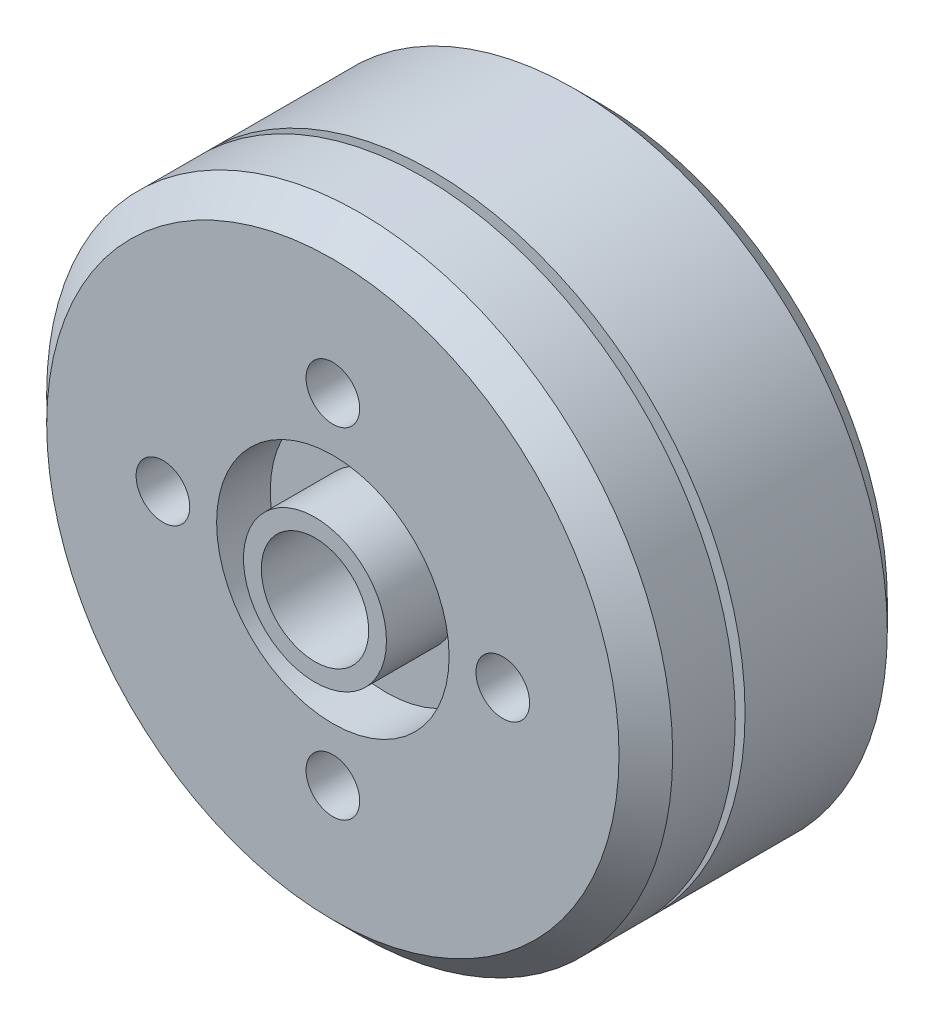
from build123d import *

# Parameters (mm, degrees)
SKETCH_1_R          = 17.5
EXTRUDE_1_DEPTH     = 15
SKETCH_2_R          = 1.5
CUT_EXTRUDE_1_DEPTH = 5
SKETCH_4_R          = 3
CUT_EXTRUDE_2_DEPTH = 20
SKETCH_5_R          = 1.5
CUT_EXTRUDE_3_DEPTH = 6
CHAMFER_1_SIZE      = 1.5
SKETCH_6_R          = 6.5
SKETCH_6_R_2        = 3.996615851
CUT_EXTRUDE_4_DEPTH = 3
SKETCH_7_R          = 3.996615851
SKETCH_7_R_2        = 3
EXTRUDE_2_DEPTH     = 1


with BuildPart() as part:
    # 草图1 → 凸台-拉伸1 (new body)
    with BuildSketch(Plane.XY):
        Circle(SKETCH_1_R)
    extrude(amount=EXTRUDE_1_DEPTH)

    # 草图2 → 切除-拉伸1 (cut)
    with BuildSketch(Plane(origin=(0, 0, 0), x_dir=(-1, 0, 0), z_dir=(0, 0, -1))):
        with Locations((0, -8)):
            Circle(SKETCH_2_R)
        with Locations((-8, 0)):
            Circle(SKETCH_2_R)
        with Locations((0, 8)):
            Circle(SKETCH_2_R)
        with Locations((8, 0)):
            Circle(SKETCH_2_R)
    extrude(amount=-CUT_EXTRUDE_1_DEPTH, mode=Mode.SUBTRACT)

    # 草图3 → 切除-旋转1 (revolve, cut)
    with BuildSketch(Plane(origin=(0, 0, 0), x_dir=(1, 0, 0), z_dir=(0, 1, 0))):
        Polygon((13.284433797, -9.953144571), (13.284433797, -10), (17.969347124, -10), (17.969347124, -9.453144571), (13.284433797, -9.453144571), align=None)
    revolve(axis=Axis((0, 0, 0), (0, 0, 1)), mode=Mode.SUBTRACT)

    # 草图4 → 切除-拉伸2 (cut)
    with BuildSketch(Plane(origin=(0, 0, 0), x_dir=(-1, 0, 0), z_dir=(0, 0, -1))):
        Circle(SKETCH_4_R)
    extrude(amount=-CUT_EXTRUDE_2_DEPTH, mode=Mode.SUBTRACT)

    # 草图5 → 切除-拉伸3 (cut)
    with BuildSketch(Plane.XY.offset(15)):
        with Locations((0, -9.5)):
            Circle(SKETCH_5_R)
        with Locations((-9.5, 0)):
            Circle(SKETCH_5_R)
        with Locations((0, 9.5)):
            Circle(SKETCH_5_R)
        with Locations((9.5, 0)):
            Circle(SKETCH_5_R)
    extrude(amount=-CUT_EXTRUDE_3_DEPTH, mode=Mode.SUBTRACT)

    # 倒角1
    chamfer_1_edges = [part.edges().sort_by_distance(p)[0] for p in [
        (-17.5, 0, 0),
        (-17.5, 0, 15),
    ]]
    chamfer(chamfer_1_edges, length=CHAMFER_1_SIZE)

    # 草图6 → 切除-拉伸4 (cut)
    with BuildSketch(Plane.XY.offset(15)):
        Circle(SKETCH_6_R)
        Circle(SKETCH_6_R_2, mode=Mode.SUBTRACT)
    extrude(amount=-CUT_EXTRUDE_4_DEPTH, mode=Mode.SUBTRACT)

    # 草图7 → 凸台-拉伸2 (add)
    with BuildSketch(Plane.XY.offset(15)):
        Circle(SKETCH_7_R)
        Circle(SKETCH_7_R_2, mode=Mode.SUBTRACT)
    extrude(amount=EXTRUDE_2_DEPTH)


solid = part.part
